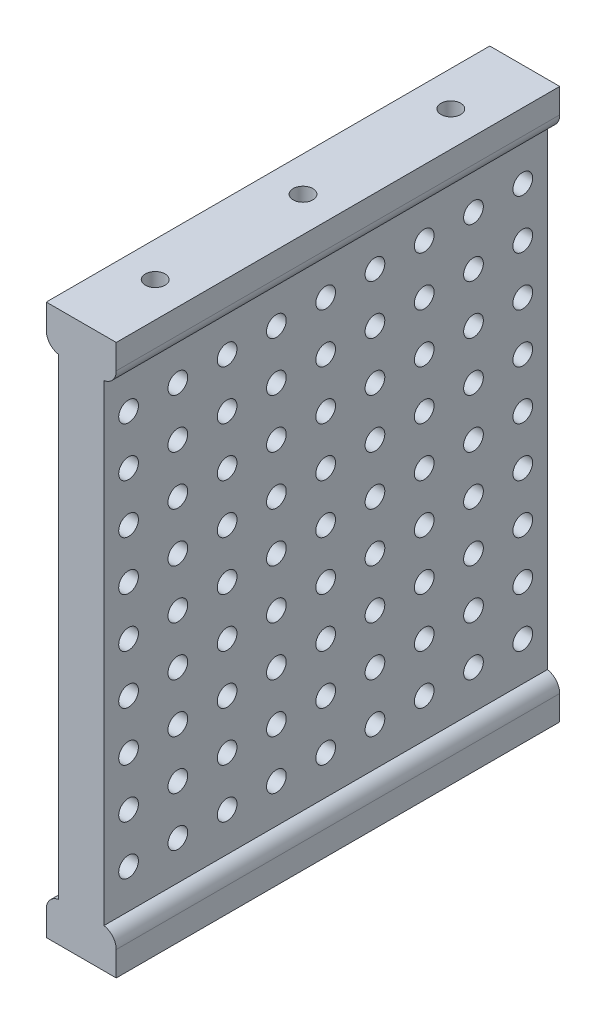
from build123d import *

# Parameters (mm, degrees)
RESSALTO_EXTRUS_O2_DEPTH   = 90
ESBO_O3_R                  = 2
CORTE_EXTRUS_O1_DEPTH      = 90
CORTE_EXTRUS_O1_DEPTH_BACK = 90
ESBO_O4_R                  = 2
CORTE_EXTRUS_O3_DEPTH      = 39
CORTE_EXTRUS_O3_DEPTH_BACK = 24


with BuildPart() as part:
    # Esboço1 → Ressalto-extrusão2 (new body)
    with BuildSketch(Plane.XY):
        with BuildLine():
            Line((10.950035456, -73.171439877), (10.950035456, 22.61248034))
            ThreePointArc((10.950035456, 22.61248034), (12.741323303, 23.634028558), (13.450035456, 25.570520231))
            Line((13.450035456, 25.570520231), (13.450035456, 30.570520231))
            Line((13.450035456, 30.570520231), (-0.749964544, 30.570520231))
            Line((-0.749964544, 30.570520231), (-0.749964544, 25.570520231))
            ThreePointArc((-0.749964544, 25.570520231), (-0.041252392, 23.634028558), (1.750035456, 22.61248034))
            Line((1.750035456, 22.61248034), (1.750035456, -73.129479769))
            Line((1.750035456, -73.129479769), (1.750035456, -73.171439877))
            ThreePointArc((1.750035456, -73.171439877), (-0.041252392, -74.192988096), (-0.749964544, -76.129479769))
            Line((-0.749964544, -76.129479769), (-0.749964544, -81.129479769))
            Line((-0.749964544, -81.129479769), (13.450035456, -81.129479769))
            Line((13.450035456, -81.129479769), (13.450035456, -76.129479769))
            ThreePointArc((13.450035456, -76.129479769), (12.741323303, -74.192988096), (10.950035456, -73.171439877))
        make_face()
    extrude(amount=RESSALTO_EXTRUS_O2_DEPTH)

    # Esboço3 → Corte-extrusão1 (cut, two sides)
    with BuildSketch(Plane(origin=(0, 0, 0), x_dir=(1, 0, 0), z_dir=(0, 1, 0))) as corte_extrus_o1_sk:
        with Locations((6.350035456, -45)):
            Circle(ESBO_O3_R)
        with Locations((6.350035456, -15)):
            Circle(ESBO_O3_R)
        with Locations((6.350035456, -75)):
            Circle(ESBO_O3_R)
    extrude(amount=CORTE_EXTRUS_O1_DEPTH, mode=Mode.SUBTRACT)
    extrude(corte_extrus_o1_sk.sketch, amount=-CORTE_EXTRUS_O1_DEPTH_BACK, mode=Mode.SUBTRACT)

    # Esboço4 → Corte-extrusão3 (cut, two sides)
    with BuildSketch(Plane(origin=(0, 0, 0), x_dir=(0, 0, -1), z_dir=(1, 0, 0))) as corte_extrus_o3_sk:
        with Locations((-45, -25.279479769)):
            Circle(ESBO_O4_R)
        with Locations((-35, -25.279479769)):
            Circle(ESBO_O4_R)
        with Locations((-25, -25.279479769)):
            Circle(ESBO_O4_R)
        with Locations((-15, -25.279479769)):
            Circle(ESBO_O4_R)
        with Locations((-5, -25.279479769)):
            Circle(ESBO_O4_R)
        with Locations((-35, -35.279479769)):
            Circle(ESBO_O4_R)
        with Locations((-25, -35.279479769)):
            Circle(ESBO_O4_R)
        with Locations((-15, -35.279479769)):
            Circle(ESBO_O4_R)
        with Locations((-5, -35.279479769)):
            Circle(ESBO_O4_R)
        with Locations((-35, -45.279479769)):
            Circle(ESBO_O4_R)
        with Locations((-25, -45.279479769)):
            Circle(ESBO_O4_R)
        with Locations((-15, -45.279479769)):
            Circle(ESBO_O4_R)
        with Locations((-5, -45.279479769)):
            Circle(ESBO_O4_R)
        with Locations((-35, -55.279479769)):
            Circle(ESBO_O4_R)
        with Locations((-25, -55.279479769)):
            Circle(ESBO_O4_R)
        with Locations((-15, -55.279479769)):
            Circle(ESBO_O4_R)
        with Locations((-5, -55.279479769)):
            Circle(ESBO_O4_R)
        with Locations((-35, -65.279479769)):
            Circle(ESBO_O4_R)
        with Locations((-25, -65.279479769)):
            Circle(ESBO_O4_R)
        with Locations((-15, -65.279479769)):
            Circle(ESBO_O4_R)
        with Locations((-5, -65.279479769)):
            Circle(ESBO_O4_R)
        with Locations((-45, -35.279479769)):
            Circle(ESBO_O4_R)
        with Locations((-45, -45.279479769)):
            Circle(ESBO_O4_R)
        with Locations((-45, -55.279479769)):
            Circle(ESBO_O4_R)
        with Locations((-45, -65.279479769)):
            Circle(ESBO_O4_R)
        with Locations((-55, -25.279479769)):
            Circle(ESBO_O4_R)
        with Locations((-65, -25.279479769)):
            Circle(ESBO_O4_R)
        with Locations((-75, -25.279479769)):
            Circle(ESBO_O4_R)
        with Locations((-85, -25.279479769)):
            Circle(ESBO_O4_R)
        with Locations((-55, -15.279479769)):
            Circle(ESBO_O4_R)
        with Locations((-65, -15.279479769)):
            Circle(ESBO_O4_R)
        with Locations((-75, -15.279479769)):
            Circle(ESBO_O4_R)
        with Locations((-85, -15.279479769)):
            Circle(ESBO_O4_R)
        with Locations((-55, -5.279479769)):
            Circle(ESBO_O4_R)
        with Locations((-65, -5.279479769)):
            Circle(ESBO_O4_R)
        with Locations((-75, -5.279479769)):
            Circle(ESBO_O4_R)
        with Locations((-85, -5.279479769)):
            Circle(ESBO_O4_R)
        with Locations((-55, 4.720520231)):
            Circle(ESBO_O4_R)
        with Locations((-65, 4.720520231)):
            Circle(ESBO_O4_R)
        with Locations((-75, 4.720520231)):
            Circle(ESBO_O4_R)
        with Locations((-85, 4.720520231)):
            Circle(ESBO_O4_R)
        with Locations((-55, 14.720520231)):
            Circle(ESBO_O4_R)
        with Locations((-65, 14.720520231)):
            Circle(ESBO_O4_R)
        with Locations((-75, 14.720520231)):
            Circle(ESBO_O4_R)
        with Locations((-85, 14.720520231)):
            Circle(ESBO_O4_R)
        with Locations((-45, -15.279479769)):
            Circle(ESBO_O4_R)
        with Locations((-45, -5.279479769)):
            Circle(ESBO_O4_R)
        with Locations((-45, 4.720520231)):
            Circle(ESBO_O4_R)
        with Locations((-45, 14.720520231)):
            Circle(ESBO_O4_R)
        with Locations((-35, -15.279479769)):
            Circle(ESBO_O4_R)
        with Locations((-35, -5.279479769)):
            Circle(ESBO_O4_R)
        with Locations((-35, 4.720520231)):
            Circle(ESBO_O4_R)
        with Locations((-35, 14.720520231)):
            Circle(ESBO_O4_R)
        with Locations((-25, -15.279479769)):
            Circle(ESBO_O4_R)
        with Locations((-25, -5.279479769)):
            Circle(ESBO_O4_R)
        with Locations((-25, 4.720520231)):
            Circle(ESBO_O4_R)
        with Locations((-25, 14.720520231)):
            Circle(ESBO_O4_R)
        with Locations((-15, -15.279479769)):
            Circle(ESBO_O4_R)
        with Locations((-15, -5.279479769)):
            Circle(ESBO_O4_R)
        with Locations((-15, 4.720520231)):
            Circle(ESBO_O4_R)
        with Locations((-15, 14.720520231)):
            Circle(ESBO_O4_R)
        with Locations((-5, -15.279479769)):
            Circle(ESBO_O4_R)
        with Locations((-5, -5.279479769)):
            Circle(ESBO_O4_R)
        with Locations((-5, 4.720520231)):
            Circle(ESBO_O4_R)
        with Locations((-5, 14.720520231)):
            Circle(ESBO_O4_R)
        with Locations((-55, -35.279479769)):
            Circle(ESBO_O4_R)
        with Locations((-55, -45.279479769)):
            Circle(ESBO_O4_R)
        with Locations((-55, -55.279479769)):
            Circle(ESBO_O4_R)
        with Locations((-55, -65.279479769)):
            Circle(ESBO_O4_R)
        with Locations((-65, -35.279479769)):
            Circle(ESBO_O4_R)
        with Locations((-65, -45.279479769)):
            Circle(ESBO_O4_R)
        with Locations((-65, -55.279479769)):
            Circle(ESBO_O4_R)
        with Locations((-65, -65.279479769)):
            Circle(ESBO_O4_R)
        with Locations((-75, -35.279479769)):
            Circle(ESBO_O4_R)
        with Locations((-75, -45.279479769)):
            Circle(ESBO_O4_R)
        with Locations((-75, -55.279479769)):
            Circle(ESBO_O4_R)
        with Locations((-75, -65.279479769)):
            Circle(ESBO_O4_R)
        with Locations((-85, -35.279479769)):
            Circle(ESBO_O4_R)
        with Locations((-85, -45.279479769)):
            Circle(ESBO_O4_R)
        with Locations((-85, -55.279479769)):
            Circle(ESBO_O4_R)
        with Locations((-85, -65.279479769)):
            Circle(ESBO_O4_R)
    extrude(amount=CORTE_EXTRUS_O3_DEPTH, mode=Mode.SUBTRACT)
    extrude(corte_extrus_o3_sk.sketch, amount=-CORTE_EXTRUS_O3_DEPTH_BACK, mode=Mode.SUBTRACT)


solid = part.part
